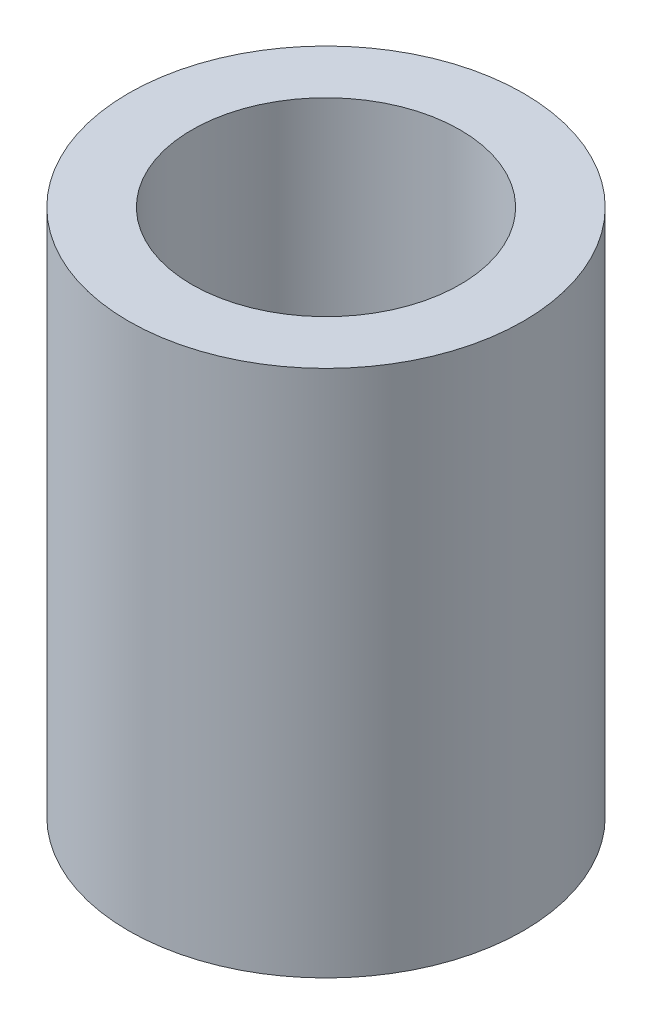
from build123d import *


with BuildPart() as part:
    # Sketch1 → Revolve1 (revolve)
    with BuildSketch(Plane.XY):
        Polygon((-2.4, 5), (-2.4, 0), (-9.35, 0), (-9.35, 25), (-6.35, 25), (-6.35, 5), align=None)
    revolve(axis=Axis((0, 0, 0), (0, -1, 0)))


solid = part.part
